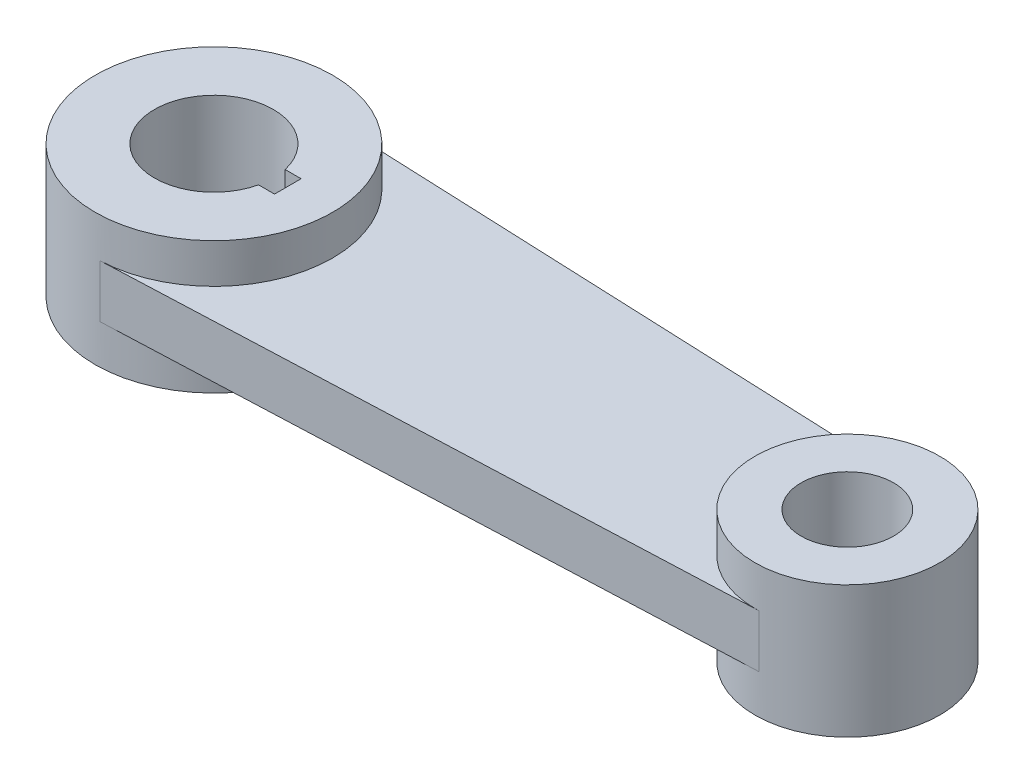
from build123d import *

# Parameters (mm, degrees)
SKETCH1_R           = 21.9
BOSS_EXTRUDE1_DEPTH = 31.25
CUT_EXTRUDE1_DEPTH  = 18.75


with BuildPart() as part:
    # Sketch1 → Boss-Extrude1 (new body, symmetric)
    with BuildSketch(Plane(origin=(0, 0, 0), x_dir=(1, 0, 0), z_dir=(0, 1, 0))):
        with BuildLine():
            Line((2.34375, 56.201150664), (301.822916667, 43.712006072))
            ThreePointArc((301.822916667, 43.712006072), (343.75, 0), (301.822916667, -43.712006072))
            Line((301.822916667, -43.712006072), (2.34375, -56.201150664))
            ThreePointArc((2.34375, -56.201150664), (-56.25, 0), (2.34375, 56.201150664))
        make_face()
        with Locations((300, 0)):
            Circle(SKETCH1_R, mode=Mode.SUBTRACT)
        with BuildLine():
            Line((27.435970914, 6.3), (35, 6.3))
            Line((35, 6.3), (35, -6.3))
            Line((35, -6.3), (27.435970914, -6.3))
            ThreePointArc((27.435970914, -6.3), (-28.15, 0), (27.435970914, 6.3))
        make_face(mode=Mode.SUBTRACT)
    extrude(amount=BOSS_EXTRUDE1_DEPTH, both=True)

    # Sketch2 → Cut-Extrude1 (cut)
    with BuildSketch(Plane(origin=(0, 31.25, 0), x_dir=(1, 0, 0), z_dir=(0, 1, 0))):
        with BuildLine():
            Line((2.34375, 56.201150664), (301.822916667, 43.712006072))
            ThreePointArc((301.822916667, 43.712006072), (256.25, 0), (301.822916667, -43.712006072))
            Line((301.822916667, -43.712006072), (2.34375, -56.201150664))
            ThreePointArc((2.34375, -56.201150664), (56.25, 0), (2.34375, 56.201150664))
        make_face()
    cut_extrude1 = extrude(amount=-CUT_EXTRUDE1_DEPTH, mode=Mode.SUBTRACT)

    # Mirror1: Cut-Extrude1 across plane
    add(cut_extrude1.mirror(Plane.ZX), mode=Mode.SUBTRACT)


solid = part.part
